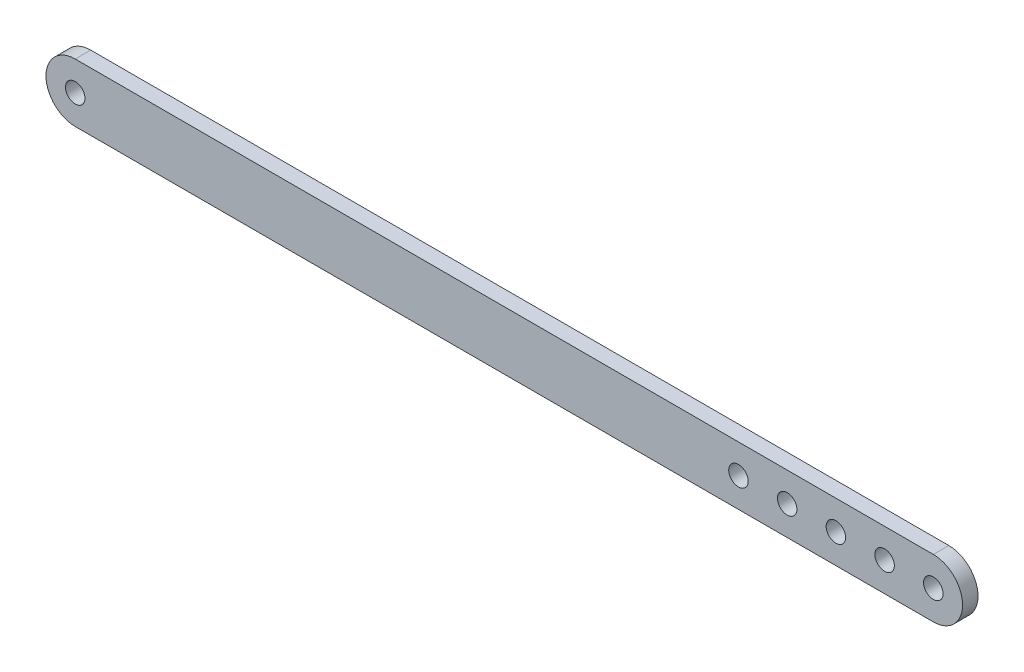
from build123d import *

# Parameters (mm, degrees)
SKETCH1_R           = 2
BOSS_EXTRUDE1_DEPTH = 3.175


with BuildPart() as part:
    # Sketch1 → Boss-Extrude1 (new body)
    with BuildSketch(Plane.XY):
        with BuildLine():
            Line((0, 6), (176.1626, 6))
            ThreePointArc((176.1626, 6), (182.1626, 0), (176.1626, -6))
            Line((176.1626, -6), (0, -6))
            ThreePointArc((0, -6), (-6, 0), (0, 6))
        make_face()
        Circle(SKETCH1_R, mode=Mode.SUBTRACT)
        with Locations((176.1626, 0)):
            Circle(SKETCH1_R, mode=Mode.SUBTRACT)
        with Locations((166.1626, 0)):
            Circle(SKETCH1_R, mode=Mode.SUBTRACT)
        with Locations((156.1626, 0)):
            Circle(SKETCH1_R, mode=Mode.SUBTRACT)
        with Locations((146.1626, 0)):
            Circle(SKETCH1_R, mode=Mode.SUBTRACT)
        with Locations((136.1626, 0)):
            Circle(SKETCH1_R, mode=Mode.SUBTRACT)
    extrude(amount=BOSS_EXTRUDE1_DEPTH)


solid = part.part
